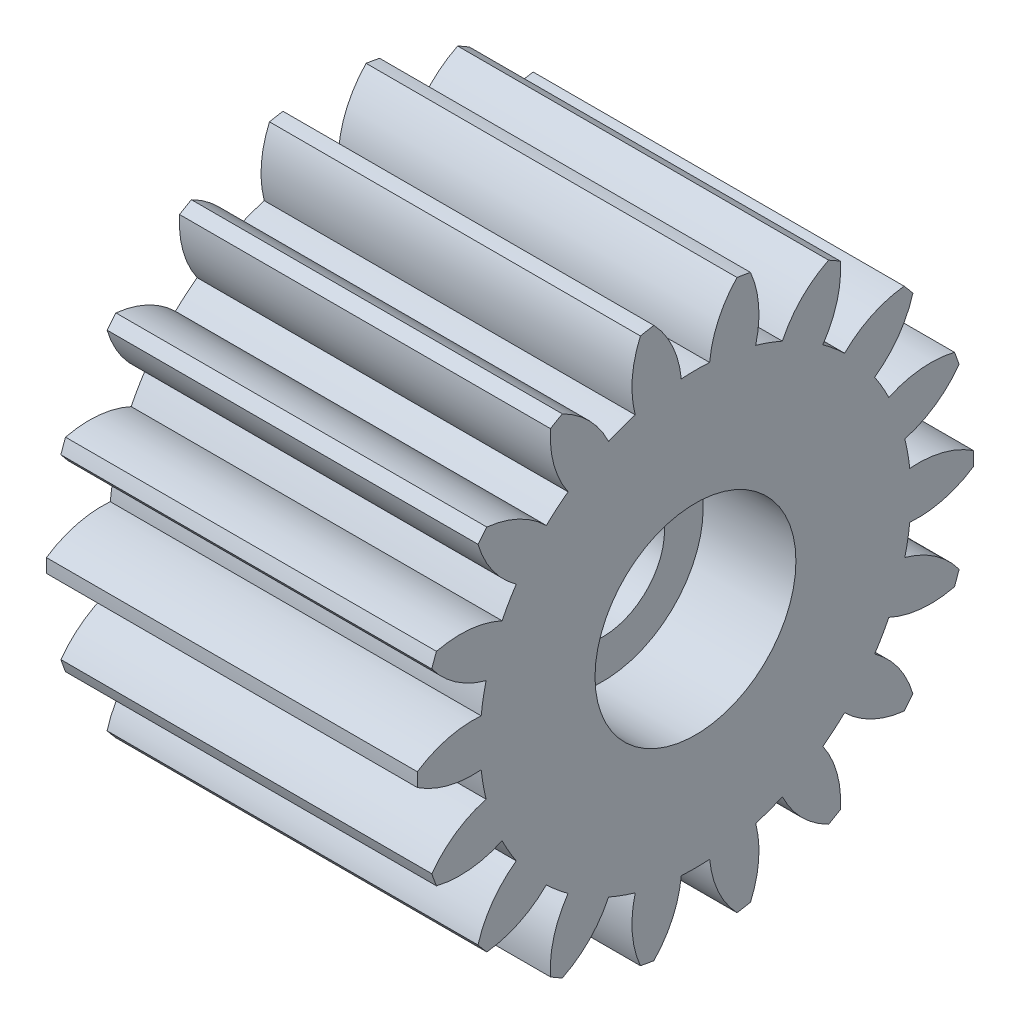
from build123d import *

# Parameters (mm, degrees)
BASPROSKE_W        = 12
BASPROSKE_H        = 9
TOOTHCUT_DEPTH     = 18.492855685
TEETHCUTS_COUNT    = 18
TEETHCUTS_ANGLE    = 340
BORSKE_R           = 2
BORE_DEPTH         = 50.0000508
SKETCH2_R          = 3.25
CUT_EXTRUDE1_DEPTH = 3
SKETCH3_R          = 4.95
CUT_EXTRUDE2_DEPTH = 4


with BuildPart() as part:
    # BasProSke → Base-Revolve (revolve)
    with BuildSketch(Plane(origin=(0, 0, 0), x_dir=(1, 0, 0), z_dir=(0, 1, 0)), mode=Mode.PRIVATE) as base_revolve_sk:
        with Locations((6, 4.5)):
            Rectangle(BASPROSKE_W, BASPROSKE_H)
    revolve(base_revolve_sk.sketch.rotate(Axis((-10, 0, 0), (1, 0, 0)), 180), axis=Axis((-10, 0, 0), (1, 0, 0)))

    # TooCutSke → ToothCut (cut, through all)
    with BuildSketch(Plane(origin=(0, 0, 0), x_dir=(0, 0, -1), z_dir=(1, 0, 0))):
        with BuildLine():
            ThreePointArc((0.45926649, 6.958861278), (0, 6.974), (-0.45926649, 6.958861278))
            ThreePointArc((-0.45926649, 6.958861278), (-0.743858876, 8.01799277), (-1.365479267, 8.921508366))
            ThreePointArc((-1.365479267, 8.921508366), (0, 9.0254), (1.365479267, 8.921508366))
            ThreePointArc((1.365479267, 8.921508366), (0.743858876, 8.01799277), (0.45926649, 6.958861278))
        make_face()
    toothcut = extrude(amount=TOOTHCUT_DEPTH, mode=Mode.SUBTRACT)

    # TeethCuts: ToothCut ×18 about axis
    teethcuts_axis = Axis((-10, 0, 0), (1, 0, 0))
    for i in range(1, TEETHCUTS_COUNT):
        add(toothcut.rotate(teethcuts_axis, i * TEETHCUTS_ANGLE / (TEETHCUTS_COUNT - 1)), mode=Mode.SUBTRACT)

    # BorSke → Bore (cut, symmetric)
    with BuildSketch(Plane(origin=(0, 0, 0), x_dir=(0, 0, -1), z_dir=(1, 0, 0))):
        with Locations(Location((0, 0, 0), (0, 0, 180))):
            Circle(BORSKE_R)
    extrude(amount=BORE_DEPTH, both=True, mode=Mode.SUBTRACT)

    # Sketch2 → Cut-Extrude1 (cut)
    with BuildSketch(Plane(origin=(12, 0, 0), x_dir=(0, 0, -1), z_dir=(1, 0, 0))):
        Circle(SKETCH2_R)
    extrude(amount=-CUT_EXTRUDE1_DEPTH, mode=Mode.SUBTRACT)

    # Sketch3 → Cut-Extrude2 (cut)
    with BuildSketch(Plane.ZY):
        Circle(SKETCH3_R)
    extrude(amount=-CUT_EXTRUDE2_DEPTH, mode=Mode.SUBTRACT)


solid = part.part
